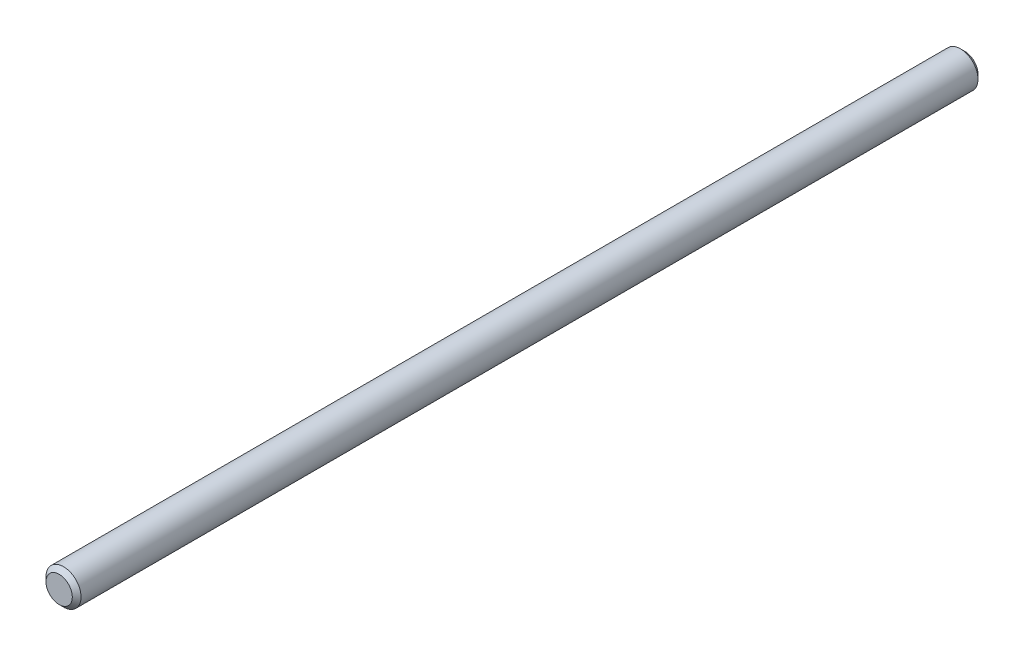
from build123d import *

# Parameters (mm, degrees)
SKETCH1_R      = 6
EXTRUDE1_DEPTH = 310
CHAMFER1_SIZE  = 1.5


with BuildPart() as part:
    # Sketch1 → Extrude1 (new body)
    with BuildSketch(Plane.XY):
        Circle(SKETCH1_R)
    extrude(amount=EXTRUDE1_DEPTH)

    # Chamfer1
    chamfer1_edges = [part.edges().sort_by_distance(p)[0] for p in [
        (-6, 0, 0),
        (-6, 0, 310),
    ]]
    chamfer(chamfer1_edges, length=CHAMFER1_SIZE)


solid = part.part
